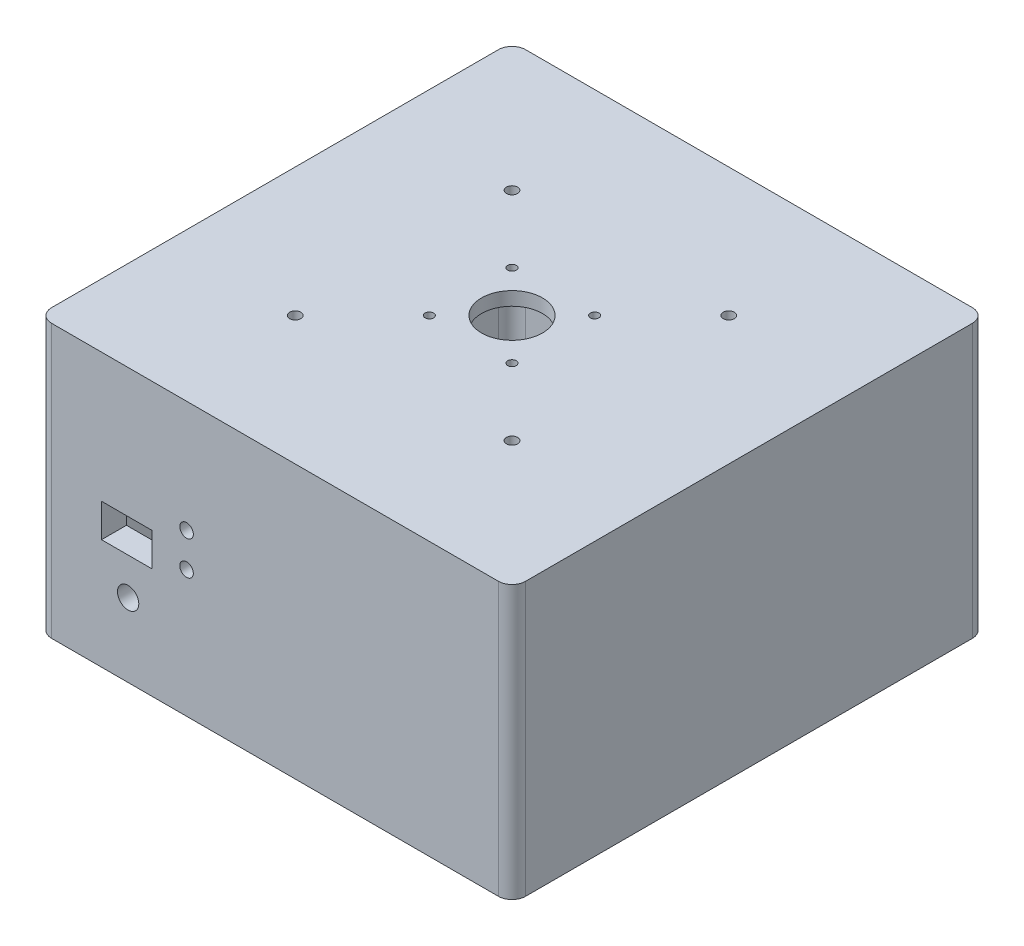
from build123d import *

# Parameters (mm, degrees)
SKETCH1_W                = 159.078855478
SKETCH1_H                = 159.078855478
BOSS_EXTRUDE1_DEPTH      = 38.1
BOSS_EXTRUDE1_DEPTH_BACK = 59.182
BOSS_EXTRUDE3_START      = 38.1
SKETCH1_5_R              = 11.43
BOSS_EXTRUDE3_DEPTH      = 5.08
SKETCH3_R                = 1.6
CUT_EXTRUDE1_DEPTH       = 163.124640459
FILLET4_R                = 5.08
SKETCH4_R                = 2.1
CUT_EXTRUDE2_DEPTH       = 5.08
SKETCH5_R                = 2.54
SKETCH5_R_2              = 4
SKETCH5_W                = 19
SKETCH5_H                = 12.5
CUT_EXTRUDE3_DEPTH       = 9.360572261
SKETCH7_W                = 25.4
SKETCH7_H                = 5.08
CUT_EXTRUDE4_DEPTH       = 5.588
BOSS_EXTRUDE4_DEPTH      = 25.4
CUT_EXTRUDE5_DEPTH       = 25.4
SKETCH11_W               = 12.7
SKETCH11_H               = 4.572
CUT_EXTRUDE6_DEPTH       = 5.334


with BuildPart() as part:
    # Sketch1 → Boss-Extrude1 (new, two sides)
    with BuildSketch(Plane(origin=(0, 0, 0), x_dir=(1, 0, 0), z_dir=(0, 1, 0))) as boss_extrude1_sk:
        with BuildLine():
            Line((-83.82, -88.9), (83.82, -88.9))
            ThreePointArc((83.82, -88.9), (87.412102448, -87.412102448), (88.9, -83.82))
            Line((88.9, -83.82), (88.9, 83.82))
            ThreePointArc((88.9, 83.82), (87.412102448, 87.412102448), (83.82, 88.9))
            Line((83.82, 88.9), (-83.82, 88.9))
            ThreePointArc((-83.82, 88.9), (-87.412102448, 87.412102448), (-88.9, 83.82))
            Line((-88.9, 83.82), (-88.9, -83.82))
            ThreePointArc((-88.9, -83.82), (-87.412102448, -87.412102448), (-83.82, -88.9))
        make_face()
        Rectangle(SKETCH1_W, SKETCH1_H, mode=Mode.SUBTRACT)
    extrude(amount=BOSS_EXTRUDE1_DEPTH)
    extrude(boss_extrude1_sk.sketch, amount=-BOSS_EXTRUDE1_DEPTH_BACK)

    # Sketch1_5 → Boss-Extrude3 (add)
    with BuildSketch(Plane(origin=(0, 0, 0), x_dir=(1, 0, 0), z_dir=(0, 1, 0)).offset(BOSS_EXTRUDE3_START)):
        with BuildLine():
            ThreePointArc((-88.9, -83.82), (-87.412102448, -87.412102448), (-83.82, -88.9))
            Line((-83.82, -88.9), (83.82, -88.9))
            ThreePointArc((83.82, -88.9), (87.412102448, -87.412102448), (88.9, -83.82))
            Line((88.9, -83.82), (88.9, 83.82))
            ThreePointArc((88.9, 83.82), (87.412102448, 87.412102448), (83.82, 88.9))
            Line((83.82, 88.9), (-83.82, 88.9))
            ThreePointArc((-83.82, 88.9), (-87.412102448, 87.412102448), (-88.9, 83.82))
            Line((-88.9, 83.82), (-88.9, -83.82))
        make_face()
        with Locations(Location((0, 0, 0), (0, 0, 270))):
            Circle(SKETCH1_5_R, mode=Mode.SUBTRACT)
    extrude(amount=BOSS_EXTRUDE3_DEPTH)

    # Sketch3 → Cut-Extrude1 (cut, through all)
    with BuildSketch(Plane(origin=(0, 43.18, 0), x_dir=(1, 0, 0), z_dir=(0, 1, 0))):
        with Locations(Location((-15.5, 15.5, 0), (0, 0, 270))):
            Circle(SKETCH3_R)
        with Locations(Location((-15.5, -15.5, 0), (0, 0, 270))):
            Circle(SKETCH3_R)
        with Locations(Location((15.5, 15.5, 0), (0, 0, 270))):
            Circle(SKETCH3_R)
        with Locations(Location((15.5, -15.5, 0), (0, 0, 270))):
            Circle(SKETCH3_R)
    extrude(amount=-CUT_EXTRUDE1_DEPTH, mode=Mode.SUBTRACT)

    # Fillet4
    fillet4_edges = [part.edges().sort_by_distance(p)[0] for p in [
        (79.539427739, -10.541, -79.539427739),
        (-79.539427739, -10.541, -79.539427739),
        (-79.539427739, -10.541, 79.539427739),
        (79.539427739, -10.541, 79.539427739),
    ]]
    fillet(fillet4_edges, radius=FILLET4_R)

    # Sketch4 → Cut-Extrude2 (cut)
    with BuildSketch(Plane(origin=(0, 43.18, 0), x_dir=(1, 0, 0), z_dir=(0, 1, 0))):
        with Locations(Location((-40.66, 40.66, 0), (0, 0, 270))):
            Circle(SKETCH4_R)
        with Locations(Location((40.66, 40.66, 0), (0, 0, 270))):
            Circle(SKETCH4_R)
        with Locations(Location((-40.66, -40.66, 0), (0, 0, 270))):
            Circle(SKETCH4_R)
        with Locations(Location((40.66, -40.66, 0), (0, 0, 270))):
            Circle(SKETCH4_R)
    extrude(amount=-CUT_EXTRUDE2_DEPTH, mode=Mode.SUBTRACT)

    # Sketch5 → Cut-Extrude3 (cut)
    with BuildSketch(Plane.XY.offset(88.9)):
        with Locations((-33.187618463, -11.513006866)):
            Circle(SKETCH5_R)
        with Locations((-33.187618463, 1.206455413)):
            Circle(SKETCH5_R)
        with Locations((-55.102312512, -31.62532479)):
            Circle(SKETCH5_R_2)
        with Locations((-55.584910431, -11.513006866)):
            Rectangle(SKETCH5_W, SKETCH5_H)
    extrude(amount=-CUT_EXTRUDE3_DEPTH, mode=Mode.SUBTRACT)

    # Sketch7 → Cut-Extrude4 (cut)
    with BuildSketch(Plane.XZ.offset(59.182)):
        with Locations((0, -82.079427739)):
            Rectangle(SKETCH7_W, SKETCH7_H)
    extrude(amount=-CUT_EXTRUDE4_DEPTH, mode=Mode.SUBTRACT)

    # Sketch10 → Boss-Extrude4 (add)
    with BuildSketch(Plane.ZY.offset(-12.7)):
        Polygon((-79.539427739, -46.736), (-79.539427739, -49.53), (-81.063427739, -49.53), align=None)
    extrude(amount=BOSS_EXTRUDE4_DEPTH)

    # Sketch10_2 → Cut-Extrude5 (cut)
    with BuildSketch(Plane.ZY.offset(-12.7)):
        Polygon((-79.539427739, -46.736), (-79.539427739, -49.53), (-81.063427739, -49.53), align=None)
    extrude(amount=CUT_EXTRUDE5_DEPTH, mode=Mode.SUBTRACT)

    # Sketch11 → Cut-Extrude6 (cut)
    with BuildSketch(Plane(origin=(0, 0, 79.539427739), x_dir=(-1, 0, 0), z_dir=(0, 0, -1))):
        with Locations((-44.45, -51.816)):
            Rectangle(SKETCH11_W, SKETCH11_H)
        with Locations((44.45, -51.816)):
            Rectangle(SKETCH11_W, SKETCH11_H)
    extrude(amount=-CUT_EXTRUDE6_DEPTH, mode=Mode.SUBTRACT)


solid = part.part
